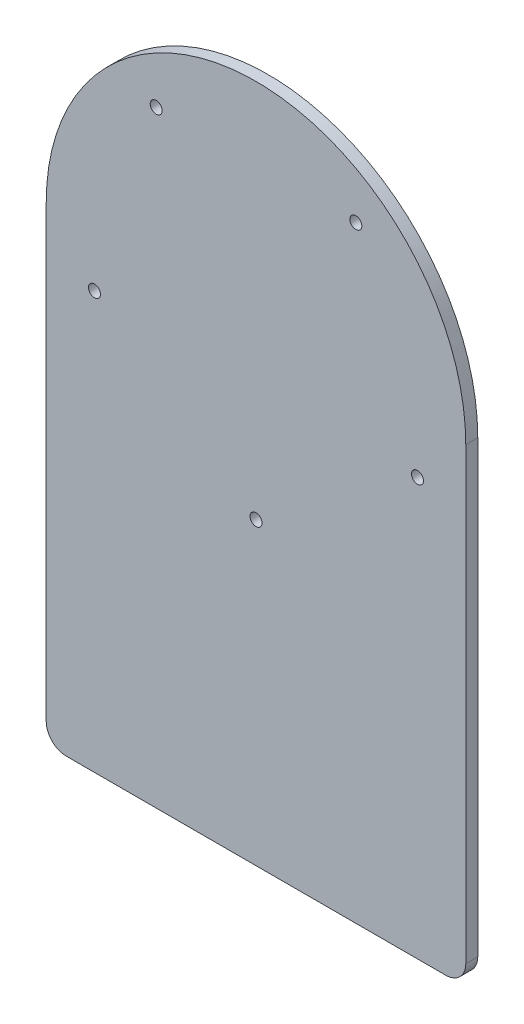
from build123d import *

# Parameters (mm, degrees)
SALIENTE_EXTRUIR1_DEPTH = 3
REDONDEO1_R             = 5
CROQUIS2_R              = 1.5
CORTAR_EXTRUIR1_DEPTH   = 3


with BuildPart() as part:
    # Croquis1 → Saliente-Extruir1 (new body)
    with BuildSketch(Plane.XY):
        with BuildLine():
            ThreePointArc((52.5, 0), (0, -52.5), (-52.5, 0))
            Line((-52.5, 0), (-52.5, -117.5))
            Line((-52.5, -117.5), (52.5, -117.5))
            Line((52.5, -117.5), (52.5, 0))
        make_face()
        with BuildLine():
            ThreePointArc((52.5, 0), (0, 52.5), (-52.5, 0))
            Line((-52.5, 0), (52.5, 0))
        make_face()
        with BuildLine():
            Line((52.5, 0), (-52.5, 0))
            ThreePointArc((-52.5, 0), (0, -52.5), (52.5, 0))
        make_face()
    extrude(amount=SALIENTE_EXTRUIR1_DEPTH)

    # Redondeo1
    redondeo1_edges = [part.edges().sort_by_distance(p)[0] for p in [
        (52.5, -117.5, 1.5),
        (-52.5, -117.5, 1.5),
    ]]
    fillet(redondeo1_edges, radius=REDONDEO1_R)

    # Croquis2 → Cortar-Extruir1 (cut)
    with BuildSketch(Plane.XY.offset(3)):
        with Locations((0, -42.5)):
            Circle(CROQUIS2_R)
        with Locations((-40.419901943, -13.133222261)):
            Circle(CROQUIS2_R)
        with Locations((-24.980873222, 34.383222261)):
            Circle(CROQUIS2_R)
        with Locations((24.980873222, 34.383222261)):
            Circle(CROQUIS2_R)
        with Locations((40.419901943, -13.133222261)):
            Circle(CROQUIS2_R)
    extrude(amount=-CORTAR_EXTRUIR1_DEPTH, mode=Mode.SUBTRACT)


solid = part.part
